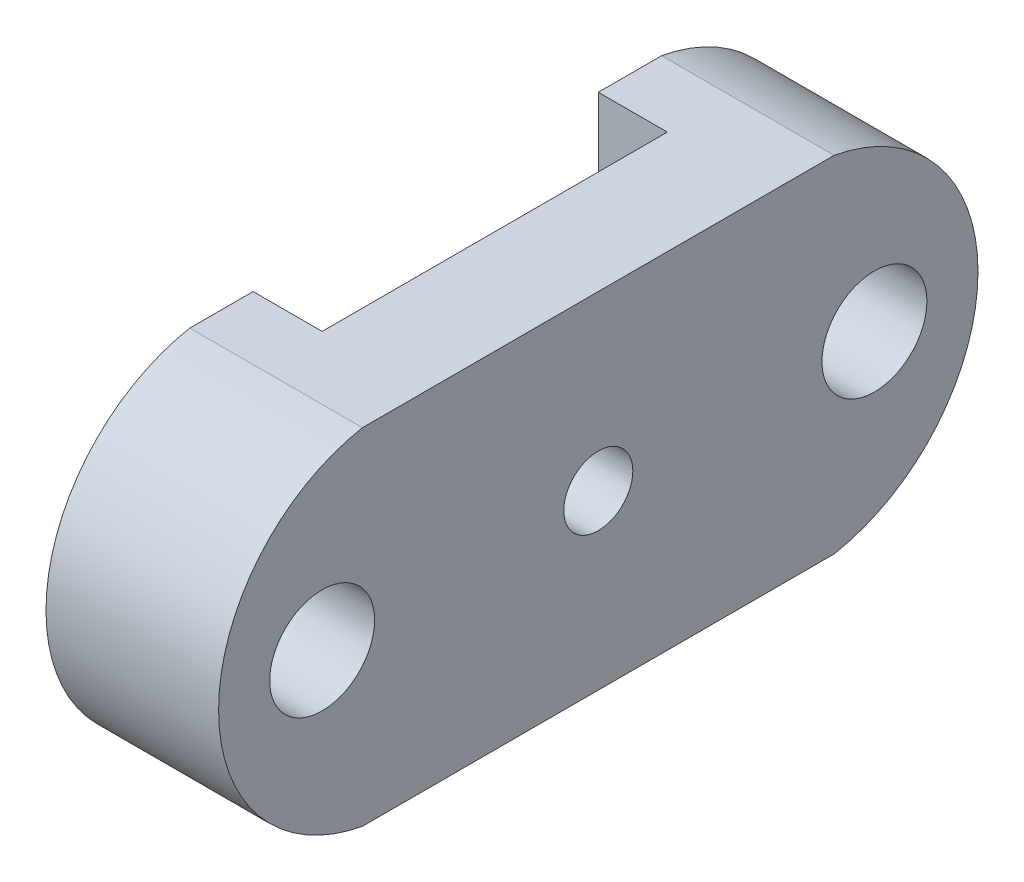
from build123d import *

# Parameters (mm, degrees)
SKETCH1_W                       = 110
SKETCH1_H                       = 50
BOSS_EXTRUDE1_DEPTH             = 25
SKETCH2_R                       = 7.6
CUT_EXTRUDE1_DEPTH              = 26
M8_CLEARANCE_HOLE1_D            = 10
M8_CLEARANCE_HOLE1_DEPTH        = 25
M8_CLEARANCE_HOLE1_TIP          = 3.004303095
SKETCH5_W                       = 10
SKETCH5_H                       = 50
CUT_EXTRUDE2_DEPTH              = 51
SKETCH6_W                       = 13
SKETCH6_H                       = 15
CUT_EXTRUDE3_DEPTH              = 6.8
CUT_EXTRUDE4_DEPTH              = 25
TAP_DRILL_FOR_M3X0_5_TAP1_D     = 2.5
TAP_DRILL_FOR_M3X0_5_TAP1_DEPTH = 32.5
TAP_DRILL_FOR_M3X0_5_TAP1_TIP   = 0.751075774


with BuildPart() as part:
    # Sketch1 → Boss-Extrude1 (new body)
    with BuildSketch(Plane(origin=(0, 0, 0), x_dir=(0, 0, -1), z_dir=(1, 0, 0))):
        Rectangle(SKETCH1_W, SKETCH1_H)
    extrude(amount=BOSS_EXTRUDE1_DEPTH)

    # Sketch2 → Cut-Extrude1 (cut, through all)
    with BuildSketch(Plane(origin=(25, 0, 0), x_dir=(0, 0, -1), z_dir=(1, 0, 0))):
        with Locations((-40, -0.006913882)):
            Circle(SKETCH2_R)
        with Locations((40, -0.006913882)):
            Circle(SKETCH2_R)
    extrude(amount=-CUT_EXTRUDE1_DEPTH, mode=Mode.SUBTRACT)

    # M8 Clearance Hole1
    with Locations(Plane(origin=(25, 0, 0), x_dir=(0, 0, -1), z_dir=(1, 0, 0))):
        with Locations((0, 0)):
            Hole(M8_CLEARANCE_HOLE1_D / 2, depth=M8_CLEARANCE_HOLE1_DEPTH)
            with Locations((0, 0, -(M8_CLEARANCE_HOLE1_DEPTH + M8_CLEARANCE_HOLE1_TIP / 2))):  # 118° drill point
                Cone(0, M8_CLEARANCE_HOLE1_D / 2, M8_CLEARANCE_HOLE1_TIP, mode=Mode.SUBTRACT)

    # Sketch5 → Cut-Extrude2 (cut, through all)
    with BuildSketch(Plane.XZ.offset(25)):
        with Locations((5, 0)):
            Rectangle(SKETCH5_W, SKETCH5_H)
    extrude(amount=-CUT_EXTRUDE2_DEPTH, mode=Mode.SUBTRACT)

    # Sketch6 → Cut-Extrude3 (cut)
    with BuildSketch(Plane.ZY.offset(-10)):
        Rectangle(SKETCH6_W, SKETCH6_H)
    extrude(amount=-CUT_EXTRUDE3_DEPTH, mode=Mode.SUBTRACT)

    # Sketch7 → Cut-Extrude4 (cut)
    with BuildSketch(Plane.ZY):
        with BuildLine():
            Line((-25, -25), (-25.995843668, -36.367385103))
            Line((-25.995843668, -36.367385103), (-60.780158428, -28.692554088))
            Line((-60.780158428, -28.692554088), (-59.294707264, 34.562907985))
            Line((-59.294707264, 34.562907985), (-23.260411868, 33.716701439))
            Line((-23.260411868, 33.716701439), (-25, 25))
            ThreePointArc((-25, 25), (-55, 0), (-25, -25))
        make_face()
        with BuildLine():
            Line((25, -25), (27.231233017, -36.367385103))
            Line((27.231233017, -36.367385103), (50.619615813, -36.367385103))
            Line((50.619615813, -36.367385103), (65.908125779, -26.522621757))
            Line((65.908125779, -26.522621757), (65.908125779, 30.480233283))
            Line((65.908125779, 30.480233283), (20.447589522, 40.50382591))
            Line((20.447589522, 40.50382591), (25, 25))
            ThreePointArc((25, 25), (55, 0), (25, -25))
        make_face()
    extrude(amount=-CUT_EXTRUDE4_DEPTH, mode=Mode.SUBTRACT)

    # Tap Drill for M3x0.5 Tap1
    with Locations(Plane(origin=(0, -25, 0), x_dir=(-1, 0, 0), z_dir=(0, -1, 0))):
        with Locations((-16.984771765, 19), (-16.984771765, -19)):
            Hole(TAP_DRILL_FOR_M3X0_5_TAP1_D / 2, depth=TAP_DRILL_FOR_M3X0_5_TAP1_DEPTH)
            with Locations((0, 0, -(TAP_DRILL_FOR_M3X0_5_TAP1_DEPTH + TAP_DRILL_FOR_M3X0_5_TAP1_TIP / 2))):  # 118° drill point
                Cone(0, TAP_DRILL_FOR_M3X0_5_TAP1_D / 2, TAP_DRILL_FOR_M3X0_5_TAP1_TIP, mode=Mode.SUBTRACT)


solid = part.part
